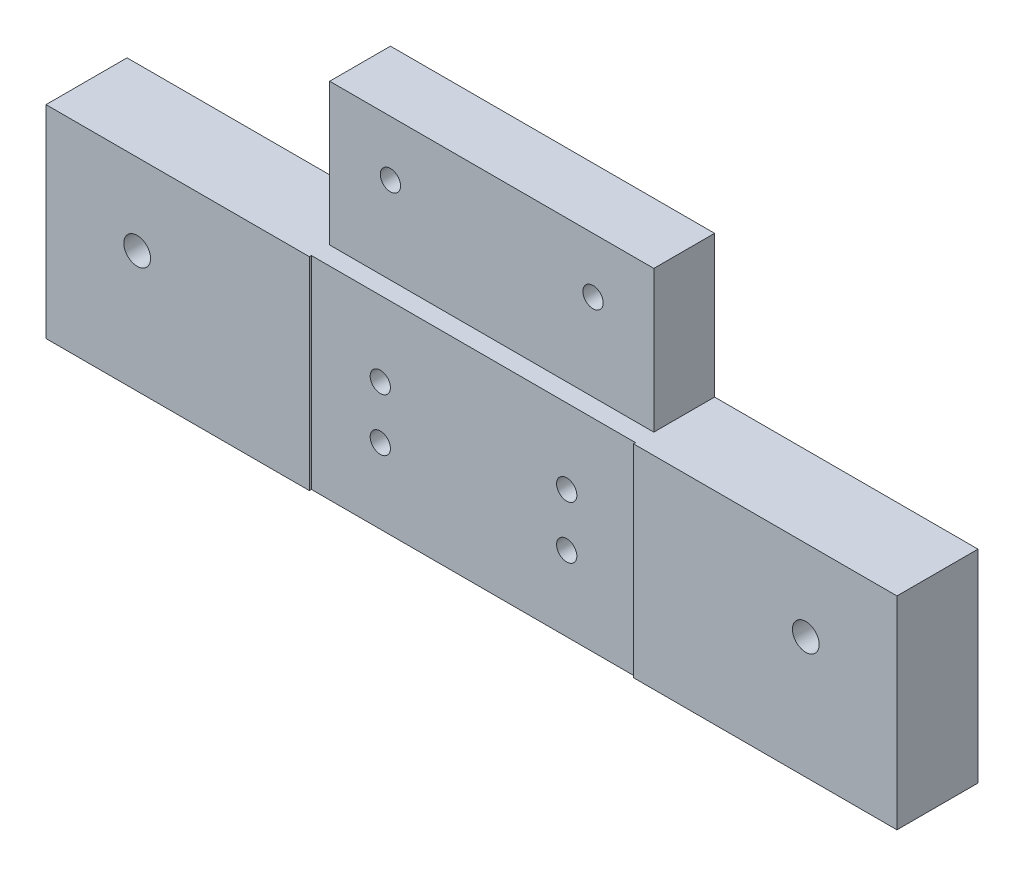
from build123d import *

# Parameters (mm, degrees)
SKETCH1_W                                      = 210
SKETCH1_H                                      = 50
EXTRUDE1_DEPTH                                 = 20
CBORE_FOR_M6_HEX_HEAD_FLANGE_BOLT1_D           = 6.6
CBORE_FOR_M6_HEX_HEAD_FLANGE_BOLT1_CBORE_D     = 16
CBORE_FOR_M6_HEX_HEAD_FLANGE_BOLT1_CBORE_DEPTH = 6.6
CUT_EXTRUDE1_REACH                             = 52
SKETCH4_W                                      = 80
SKETCH4_H                                      = 0.5
M6_TAPPED_HOLE1_D                              = 5
SKETCH7_W                                      = 80
SKETCH7_H                                      = 35
EXTRUDE2_DEPTH                                 = 19.5
SKETCH8_W                                      = 80
SKETCH8_H                                      = 5
CUT_EXTRUDE2_DEPTH                             = 35
M6_TAPPED_HOLE2_D                              = 5


with BuildPart() as part:
    # Sketch1 → Extrude1 (new body)
    with BuildSketch(Plane.XY):
        Rectangle(SKETCH1_W, SKETCH1_H)
    extrude(amount=EXTRUDE1_DEPTH)

    # CBORE for M6 Hex Head Flange Bolt1 (through all)
    with Locations(Plane(origin=(0, 0, 0), x_dir=(-1, 0, 0), z_dir=(0, 0, -1))):
        with Locations((82.5, 5), (-82.5, 5)):
            CounterBoreHole(CBORE_FOR_M6_HEX_HEAD_FLANGE_BOLT1_D / 2, CBORE_FOR_M6_HEX_HEAD_FLANGE_BOLT1_CBORE_D / 2, CBORE_FOR_M6_HEX_HEAD_FLANGE_BOLT1_CBORE_DEPTH)

    # Sketch4 → Cut-Extrude1 (cut, up to next)
    with BuildSketch(Plane(origin=(0, 25, 0), x_dir=(1, 0, 0), z_dir=(0, 1, 0)), mode=Mode.PRIVATE) as cut_extrude1_sk1:
        with Locations((0, -19.75)):
            Rectangle(SKETCH4_W, SKETCH4_H)
    cut_extrude1_tool1 = extrude(cut_extrude1_sk1.sketch, amount=-CUT_EXTRUDE1_REACH, mode=Mode.PRIVATE) & part.part
    add(cut_extrude1_tool1.solids().sort_by_distance((0, 25, 19.75))[0], mode=Mode.SUBTRACT)

    # M6 Tapped Hole1 (through all)
    with Locations(Plane.XY.offset(19.5)):
        with Locations((-23, 6.5), (-23, -6.5), (23, 6.5), (23, -6.5)):
            Hole(M6_TAPPED_HOLE1_D / 2)

    # Sketch7 → Extrude2 (add)
    with BuildSketch(Plane.XY.offset(19.5)):
        with Locations((0, 42.5)):
            Rectangle(SKETCH7_W, SKETCH7_H)
    extrude(amount=-EXTRUDE2_DEPTH)

    # Sketch8 → Cut-Extrude2 (cut)
    with BuildSketch(Plane(origin=(0, 60, 0), x_dir=(1, 0, 0), z_dir=(0, 1, 0))):
        with Locations((0, -17.5)):
            Rectangle(SKETCH8_W, SKETCH8_H)
    extrude(amount=-CUT_EXTRUDE2_DEPTH, mode=Mode.SUBTRACT)

    # M6 Tapped Hole2 (through all)
    with Locations(Plane.XY.offset(15)):
        with Locations((-25, 46.359410027), (25, 46.359410027)):
            Hole(M6_TAPPED_HOLE2_D / 2)


solid = part.part
